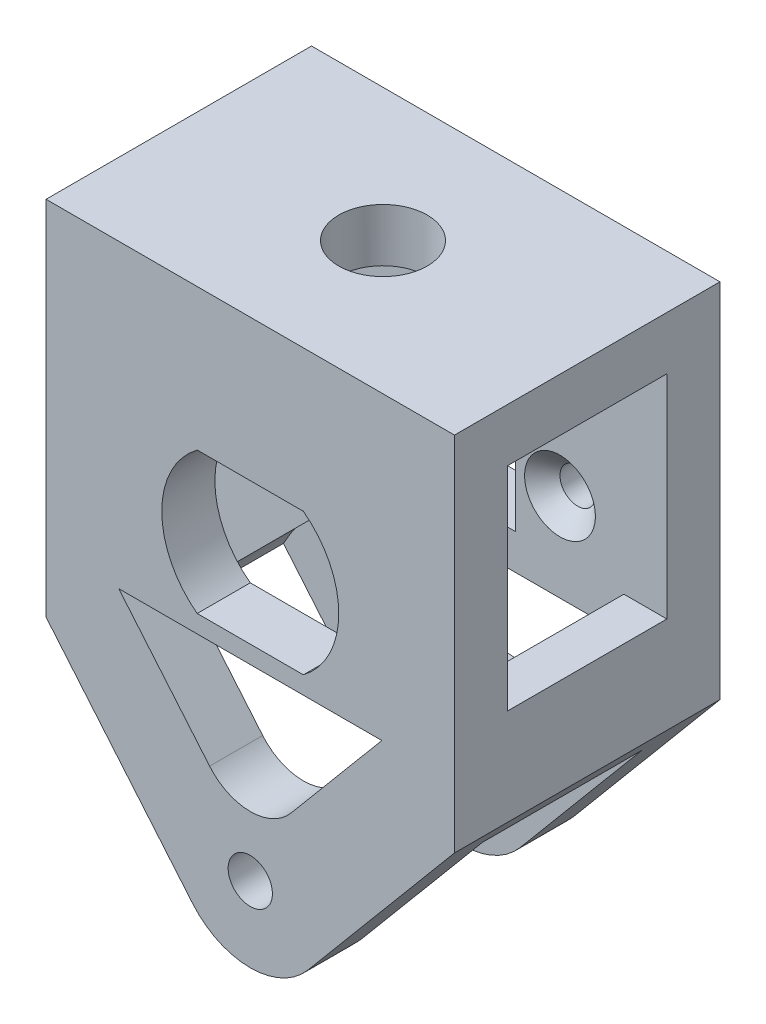
from build123d import *

# Parameters (mm, degrees)
SKETCH1_R           = 1.25
BOSS_EXTRUDE1_DEPTH = 3
BOSS_EXTRUDE2_DEPTH = 14
FILLET1_R           = 1
FILLET3_R           = 3
CUT_EXTRUDE1_DEPTH  = 15
SKETCH8_W           = 23.078375234
SKETCH8_H           = 15
BOSS_EXTRUDE6_DEPTH = 15
SKETCH9_W           = 9
SKETCH9_H           = 12
CUT_EXTRUDE4_DEPTH  = 12.5
SKETCH10_W          = 3
SKETCH10_H          = 2
BOSS_EXTRUDE8_DEPTH = 11.5
CUT_EXTRUDE5_START  = 12
CUT_EXTRUDE5_DEPTH  = 3
SKETCH12_R          = 1
SKETCH12_W          = 6
SKETCH12_H          = 6
CUT_EXTRUDE6_DEPTH  = 3
CUT_EXTRUDE7_START  = 27.589042
SKETCH13_R          = 2.5
CUT_EXTRUDE7_DEPTH  = 4
CHAMFER1_SIZE       = 1


with BuildPart() as part:
    # Sketch1 → Boss-Extrude1 (new body)
    with BuildSketch(Plane.XY):
        with BuildLine():
            Line((-16.111441077, 12.589041521), (-3.255688883, -2.731847341))
            ThreePointArc((-3.255688883, -2.731847341), (0, -4.25), (3.255688883, -2.731847341))
            Line((3.255688883, -2.731847341), (16.111441077, 12.589041521))
            Line((16.111441077, 12.589041521), (9.111441077, 12.589041521))
            Line((9.111441077, 12.589041521), (0, 1.730448884))
            Line((0, 1.730448884), (-9.111441077, 12.589041521))
            Line((-9.111441077, 12.589041521), (-16.111441077, 12.589041521))
        make_face()
        Circle(SKETCH1_R, mode=Mode.SUBTRACT)
    boss_extrude1 = extrude(amount=BOSS_EXTRUDE1_DEPTH)

    # Sketch2 → Boss-Extrude2 (add)
    with BuildSketch(Plane.XY):
        with BuildLine():
            Line((16.111441077, 12.589041521), (9.111441077, 12.589041521))
            Line((9.111441077, 12.589041521), (6.505319132, 9.483186331))
            ThreePointArc((6.505319132, 9.483186331), (8.555448033, 7.684680147), (10.124424164, 5.453992606))
            Line((10.124424164, 5.453992606), (16.111441077, 12.589041521))
        make_face()
        with BuildLine():
            Line((-9.111441077, 12.589041521), (-16.111441077, 12.589041521))
            Line((-16.111441077, 12.589041521), (-10.124424164, 5.453992606))
            ThreePointArc((-10.124424164, 5.453992606), (-8.555448033, 7.684680147), (-6.505319132, 9.483186331))
            Line((-6.505319132, 9.483186331), (-9.111441077, 12.589041521))
        make_face()
    extrude(amount=BOSS_EXTRUDE2_DEPTH)

    # Mirror1: Boss-Extrude1 across plane
    add(boss_extrude1.mirror(Plane(origin=(0, 0, 7.5), x_dir=(1, 0, 0), z_dir=(0, 0, -1))))

    # Fillet1
    fillet1_edges = [part.edges().sort_by_distance(p)[0] for p in [
        (16.111441077, 12.589041521, 7.5),
        (-16.111441077, 12.589041521, 7.5),
    ]]
    fillet(fillet1_edges, radius=FILLET1_R)

    # Fillet3
    fillet3_edges = [part.edges().sort_by_distance(p)[0] for p in [
        (0, 1.730448884, 1.5),
        (0, 1.730448884, 13.5),
    ]]
    fillet(fillet3_edges, radius=FILLET3_R)

    # Sketch5 → Cut-Extrude1 (cut)
    with BuildSketch(Plane.XY):
        Polygon((11.539187617, 12.589041521), (11.539187617, 7.140042034), (16.111441077, 12.589041521), align=None)
        Polygon((-11.539187617, 12.589041521), (-11.539187617, 7.140042034), (-16.111441077, 12.589041521), align=None)
    extrude(amount=CUT_EXTRUDE1_DEPTH, mode=Mode.SUBTRACT)

    # Sketch8 → Boss-Extrude6 (add)
    with BuildSketch(Plane.XY):
        with Locations((0, 20.089041521)):
            Rectangle(SKETCH8_W, SKETCH8_H)
    extrude(amount=BOSS_EXTRUDE6_DEPTH)

    # Sketch9 → Cut-Extrude4 (cut, symmetric)
    with BuildSketch(Plane(origin=(0, 0, 0), x_dir=(0, 0, -1), z_dir=(1, 0, 0))):
        with Locations((-7.5, 18.589041521)):
            Rectangle(SKETCH9_W, SKETCH9_H)
    extrude(amount=CUT_EXTRUDE4_DEPTH, both=True, mode=Mode.SUBTRACT)

    # Sketch10 → Boss-Extrude8 (add, symmetric)
    with BuildSketch(Plane(origin=(0, 0, 0), x_dir=(0, 0, -1), z_dir=(1, 0, 0))):
        with Locations((-13.5, 11.589041521)):
            Rectangle(SKETCH10_W, SKETCH10_H)
        with Locations((-1.5, 11.589041521)):
            Rectangle(SKETCH10_W, SKETCH10_H)
    extrude(amount=BOSS_EXTRUDE8_DEPTH, both=True)

    # Sketch11 → Cut-Extrude5 (cut)
    with BuildSketch(Plane.XY.offset(CUT_EXTRUDE5_START)):
        with BuildLine():
            Line((-3, 11.589041521), (3, 11.589041521))
            ThreePointArc((3, 11.589041521), (5, 15.589041521), (3, 19.589041521))
            Line((3, 19.589041521), (-3, 19.589041521))
            ThreePointArc((-3, 19.589041521), (-5, 15.589041521), (-3, 11.589041521))
        make_face()
    extrude(amount=CUT_EXTRUDE5_DEPTH, mode=Mode.SUBTRACT)

    # Sketch12 → Cut-Extrude6 (cut)
    with BuildSketch(Plane.XY):
        with Locations((5.5, 15.589041521)):
            Circle(SKETCH12_R)
        with Locations((-5.5, 15.589041521)):
            Circle(SKETCH12_R)
        with Locations((0, 15.589041521)):
            Rectangle(SKETCH12_W, SKETCH12_H)
    extrude(amount=CUT_EXTRUDE6_DEPTH, mode=Mode.SUBTRACT)

    # Sketch13 → Cut-Extrude7 (cut)
    with BuildSketch(Plane(origin=(0, 0, 0), x_dir=(1, 0, 0), z_dir=(0, 1, 0)).offset(CUT_EXTRUDE7_START)):
        with Locations((0, -7.5)):
            Circle(SKETCH13_R)
    extrude(amount=-CUT_EXTRUDE7_DEPTH, mode=Mode.SUBTRACT)

    # Chamfer1
    chamfer1_edges = [part.edges().sort_by_distance(p)[0] for p in [
        (-6.5, 15.589041521, 3),
        (4.5, 15.589041521, 3),
    ]]
    chamfer(chamfer1_edges, length=CHAMFER1_SIZE)


solid = part.part
